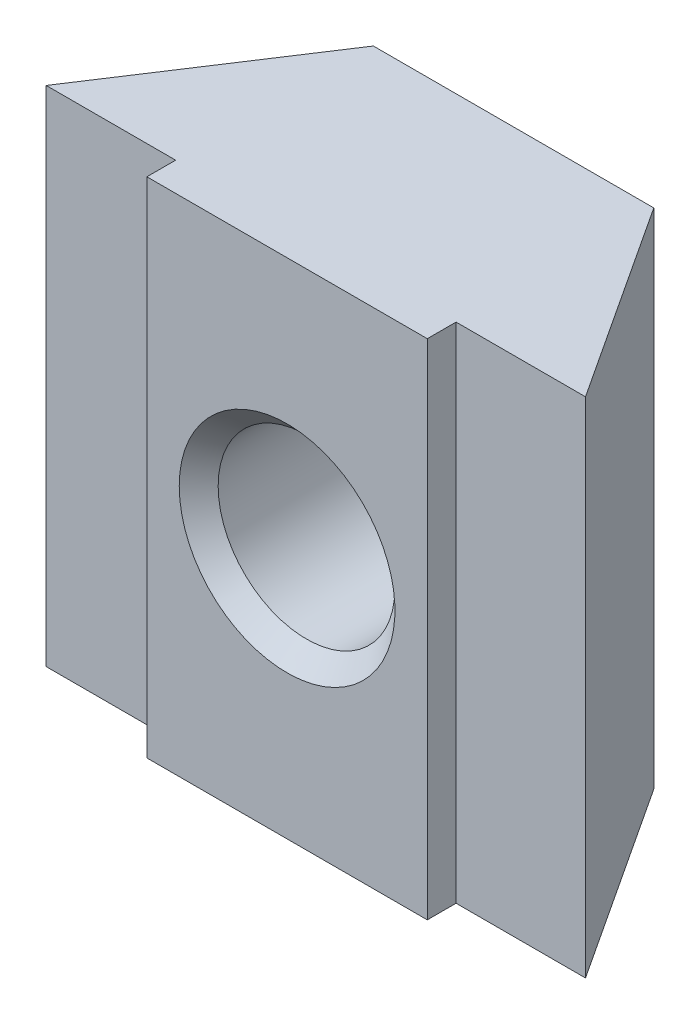
from build123d import *

# Parameters (mm, degrees)
EXTRUDE1_DEPTH = 14
SKETCH2_W      = 7.8
SKETCH2_H      = 14
EXTRUDE2_DEPTH = 0.8
HOLEWZD1_D     = 4.917
HOLEWZD1_DEPTH = 6.3
CHAMFER1_SIZE  = 0.5415


with BuildPart() as part:
    # Sketch1 → Extrude1 (new body)
    with BuildSketch(Plane(origin=(0, 28.5, 0), x_dir=(1, 0, 0), z_dir=(0, 1, 0))):
        Polygon((11.6, 15.6), (8, 10.1), (23, 10.1), (19.4, 15.6), align=None)
    extrude(amount=-EXTRUDE1_DEPTH)

    # Sketch2 → Extrude2 (add)
    with BuildSketch(Plane.XY.offset(-10.1)):
        with Locations((15.5, 21.5)):
            Rectangle(SKETCH2_W, SKETCH2_H)
    extrude(amount=EXTRUDE2_DEPTH)

    # HoleWzd1
    with Locations(Plane.XY.offset(-9.3)):
        with Locations((15.5, 21.5)):
            Hole(HOLEWZD1_D / 2, depth=HOLEWZD1_DEPTH)

    # Chamfer1
    chamfer1_edges = [part.edges().sort_by_distance(p)[0] for p in [
        (17.9585, 21.5, -9.3),
        (17.9585, 21.5, -15.6),
    ]]
    chamfer(chamfer1_edges, length=CHAMFER1_SIZE)


solid = part.part
